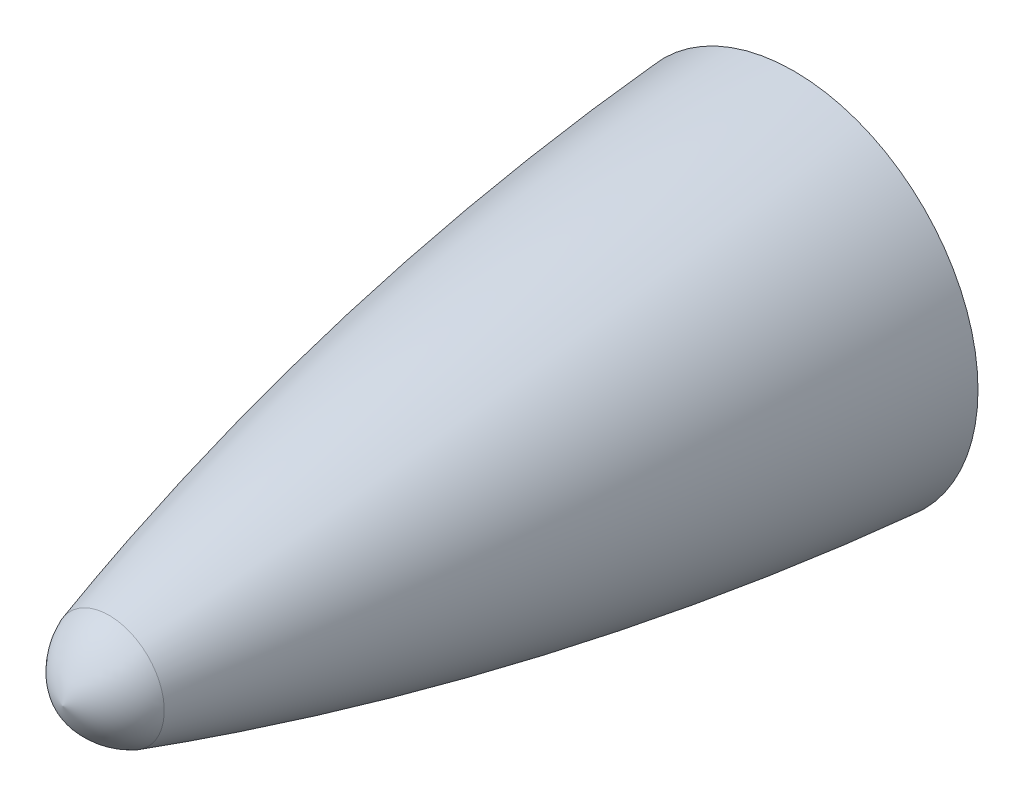
from build123d import *


with BuildPart() as part:
    # Sketch2 → Revolve1 (revolve)
    with BuildSketch(Plane(origin=(0, 0, 0), x_dir=(0, 0, -1), z_dir=(1, 0, 0))):
        with BuildLine():
            Line((-12, 0), (-35.841139357, 0))
            ThreePointArc((-35.841139357, 0), (-35.294277123, 1.078160146), (-34.322423622, 1.797179182))
            ThreePointArc((-34.322423622, 1.797179182), (-23.276329769, 4.510015091), (-12, 6))
            Line((-12, 6), (-12, 0))
        make_face()
    revolve(axis=Axis((0, 0, 12), (0, 0, 1)))


solid = part.part
